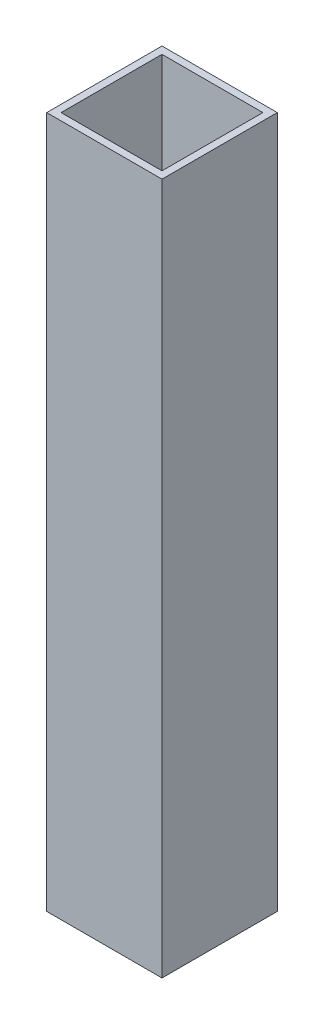
from build123d import *

# Parameters (mm, degrees)
SKETCH1_W           = 25.4
SKETCH1_H           = 25.4
SKETCH1_W_2         = 22.225
SKETCH1_H_2         = 22.225
BOSS_EXTRUDE1_DEPTH = 152.4


with BuildPart() as part:
    # Sketch1 → Boss-Extrude1 (new body)
    with BuildSketch(Plane(origin=(0, 0, 0), x_dir=(1, 0, 0), z_dir=(0, 1, 0))):
        Rectangle(SKETCH1_W, SKETCH1_H)
        Rectangle(SKETCH1_W_2, SKETCH1_H_2, mode=Mode.SUBTRACT)
    extrude(amount=BOSS_EXTRUDE1_DEPTH)


solid = part.part
